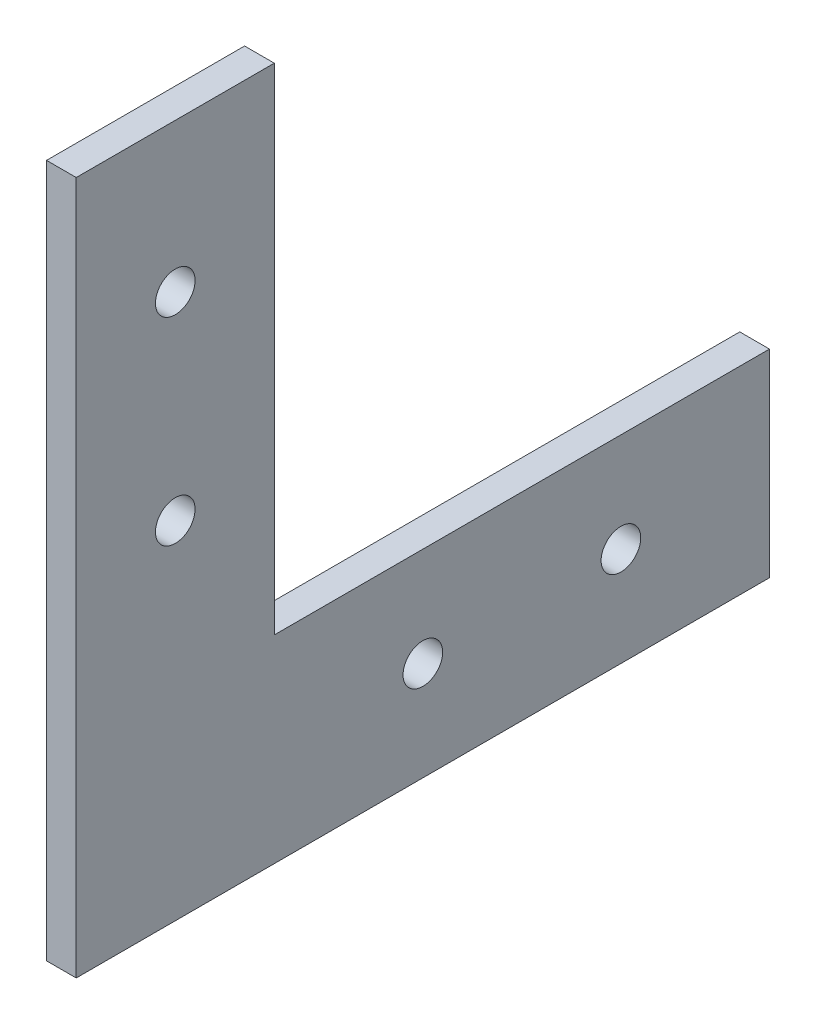
from build123d import *

# Parameters (mm, degrees)
ESBO_O1_W                = 20
ESBO_O1_H                = 50
ESBO_O1_R                = 2
ESBO_O1_W_2              = 50
ESBO_O1_H_2              = 20
RESSALTO_EXTRUS_O1_DEPTH = 3


with BuildPart() as part:
    # Esboço1 → Ressalto-extrusão1 (new body)
    with BuildSketch(Plane(origin=(0, 0, 0), x_dir=(0, 0, -1), z_dir=(1, 0, 0))):
        with Locations((10, 45)):
            Rectangle(ESBO_O1_W, ESBO_O1_H)
        with Locations((10, 35)):
            Circle(ESBO_O1_R, mode=Mode.SUBTRACT)
        with Locations((10, 55)):
            Circle(ESBO_O1_R, mode=Mode.SUBTRACT)
        with Locations((45, 10)):
            Rectangle(ESBO_O1_W_2, ESBO_O1_H_2)
        with Locations((35, 10)):
            Circle(ESBO_O1_R, mode=Mode.SUBTRACT)
        with Locations((55, 10)):
            Circle(ESBO_O1_R, mode=Mode.SUBTRACT)
        with Locations((10, 10)):
            Rectangle(ESBO_O1_W, ESBO_O1_H_2)
    extrude(amount=RESSALTO_EXTRUS_O1_DEPTH)


solid = part.part
